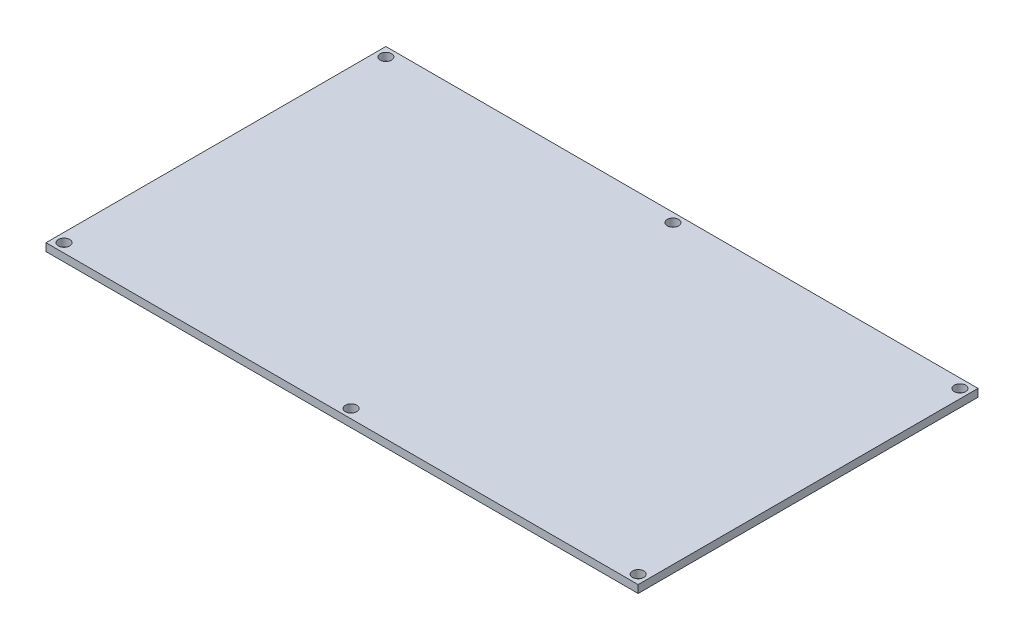
from build123d import *

# Parameters (mm, degrees)
SKETCH_1_W          = 230
SKETCH_1_H          = 132
EXTRUDE_1_DEPTH     = 3
SKETCH_2_R          = 2.2
CUT_EXTRUDE_1_DEPTH = 4


with BuildPart() as part:
    # 草图1 → 凸台-拉伸1 (new body)
    with BuildSketch(Plane(origin=(0, 0, 0), x_dir=(1, 0, 0), z_dir=(0, 1, 0))):
        Rectangle(SKETCH_1_W, SKETCH_1_H)
    extrude(amount=EXTRUDE_1_DEPTH)

    # 草图2 → 切除-拉伸1 (cut)
    with BuildSketch(Plane(origin=(0, 3, 0), x_dir=(1, 0, 0), z_dir=(0, 1, 0))):
        with Locations((-111.5, 62.5)):
            Circle(SKETCH_2_R)
        with Locations((0, 62.5)):
            Circle(SKETCH_2_R)
        with Locations((111.5, 62.5)):
            Circle(SKETCH_2_R)
        with Locations((111.5, -62.5)):
            Circle(SKETCH_2_R)
        with Locations((0, -62.5)):
            Circle(SKETCH_2_R)
        with Locations((-111.5, -62.5)):
            Circle(SKETCH_2_R)
    extrude(amount=-CUT_EXTRUDE_1_DEPTH, mode=Mode.SUBTRACT)


solid = part.part
